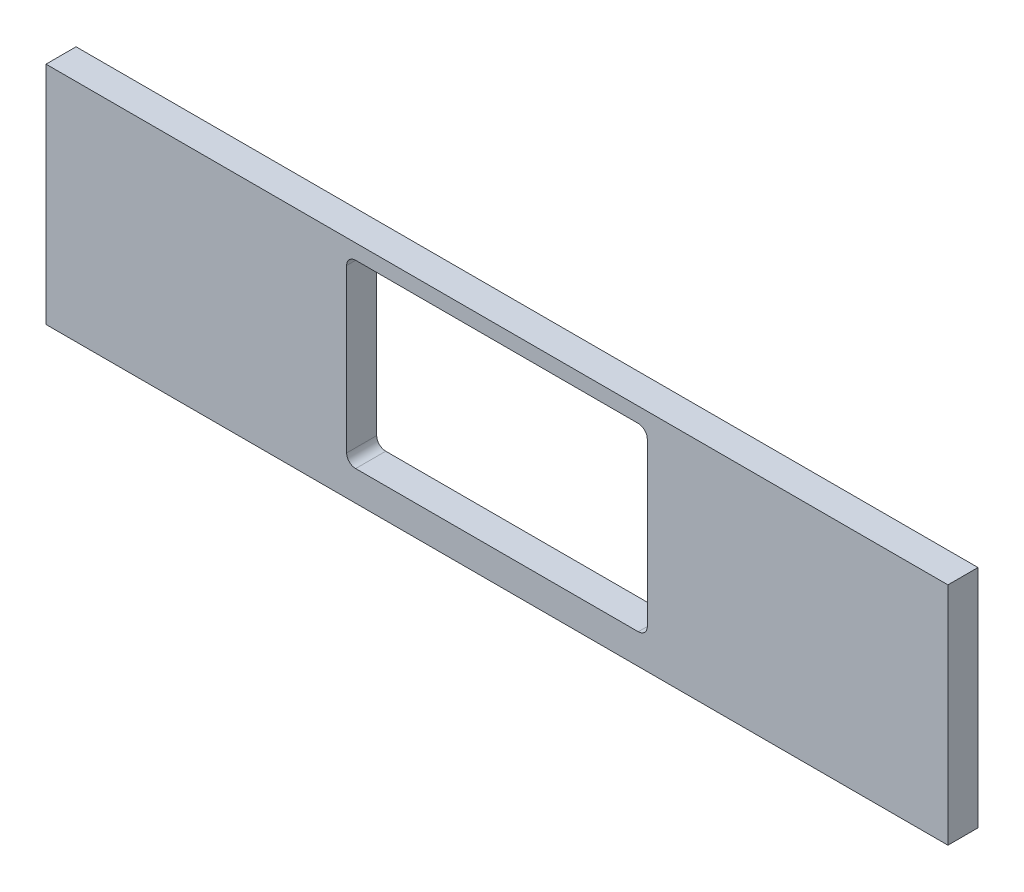
from build123d import *

# Parameters (mm, degrees)
SKIZZE1_W                       = 300
SKIZZE1_H                       = 75
LINEAR_AUSTRAGEN1_DEPTH         = 10
SKIZZE2_W                       = 100
SKIZZE2_H                       = 60
SCHNITT_LINEAR_AUSTRAGEN1_DEPTH = 10
VERRUNDUNG1_R                   = 3


with BuildPart() as part:
    # Skizze1 → Linear austragen1 (new body)
    with BuildSketch(Plane.XY):
        with Locations((0, -112.5)):
            Rectangle(SKIZZE1_W, SKIZZE1_H)
    extrude(amount=LINEAR_AUSTRAGEN1_DEPTH)

    # Skizze2 → Schnitt-Linear austragen1 (cut)
    with BuildSketch(Plane.XY.offset(10)):
        with Locations((0, -110)):
            Rectangle(SKIZZE2_W, SKIZZE2_H)
    extrude(amount=-SCHNITT_LINEAR_AUSTRAGEN1_DEPTH, mode=Mode.SUBTRACT)

    # Verrundung1
    verrundung1_edges = [part.edges().sort_by_distance(p)[0] for p in [
        (50, -80, 5),
        (50, -140, 5),
        (-50, -140, 5),
        (-50, -80, 5),
    ]]
    fillet(verrundung1_edges, radius=VERRUNDUNG1_R)


solid = part.part
